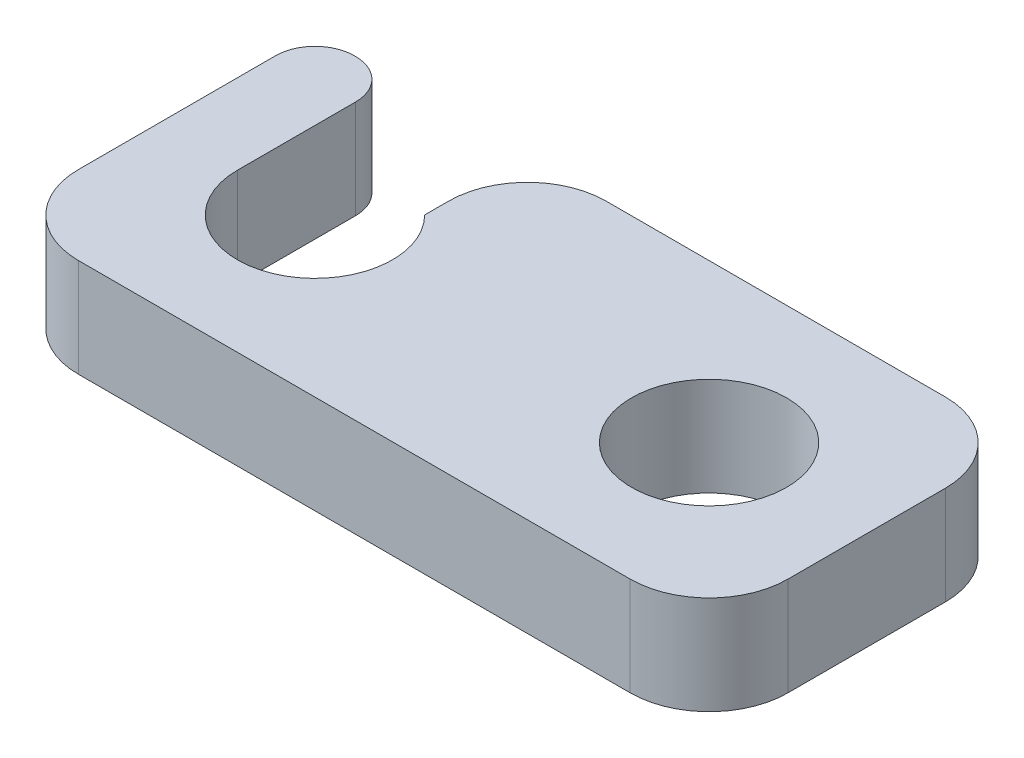
from build123d import *

# Parameters (mm, degrees)
SKETCH1_W           = 22.86
SKETCH1_H           = 10.16
BOSS_EXTRUDE1_DEPTH = 3.175
SKETCH2_R           = 2.5
CUT_EXTRUDE1_DEPTH  = 4.175
CUT_EXTRUDE2_DEPTH  = 4.175
FILLET1_R           = 2.54
FILLET2_R           = 1.27


with BuildPart() as part:
    # Sketch1 → Boss-Extrude1 (new body)
    with BuildSketch(Plane(origin=(0, 0, 0), x_dir=(1, 0, 0), z_dir=(0, 1, 0))):
        Rectangle(SKETCH1_W, SKETCH1_H)
    extrude(amount=BOSS_EXTRUDE1_DEPTH)

    # Sketch2 → Cut-Extrude1 (cut, through all)
    with BuildSketch(Plane(origin=(0, 3.175, 0), x_dir=(1, 0, 0), z_dir=(0, 1, 0))):
        with Locations((-6.35, 0)):
            Circle(SKETCH2_R)
        with Locations((6.35, 0)):
            Circle(SKETCH2_R)
    extrude(amount=-CUT_EXTRUDE1_DEPTH, mode=Mode.SUBTRACT)

    # Sketch3 → Cut-Extrude2 (cut, through all)
    with BuildSketch(Plane(origin=(0, 3.175, 0), x_dir=(1, 0, 0), z_dir=(0, 1, 0))):
        with BuildLine():
            Line((-8.85, 0), (-8.85, 5.08))
            Line((-8.85, 5.08), (-4.584545949, 5.08))
            Line((-4.584545949, 5.08), (-4.584545949, 1.770076833))
            ThreePointArc((-4.584545949, 1.770076833), (-7.308218366, 2.30907288), (-8.85, 0))
        make_face()
    extrude(amount=-CUT_EXTRUDE2_DEPTH, mode=Mode.SUBTRACT)

    # Fillet1
    fillet1_edges = [part.edges().sort_by_distance(p)[0] for p in [
        (-4.584545949, 1.5875, -5.08),
        (11.43, 1.5875, 5.08),
        (-11.43, 1.5875, 5.08),
        (11.43, 1.5875, -5.08),
    ]]
    fillet(fillet1_edges, radius=FILLET1_R)

    # Fillet2
    fillet2_edges = [part.edges().sort_by_distance(p)[0] for p in [
        (-8.85, 1.5875, -5.08),
        (-11.43, 1.5875, -5.08),
    ]]
    fillet(fillet2_edges, radius=FILLET2_R)


solid = part.part
